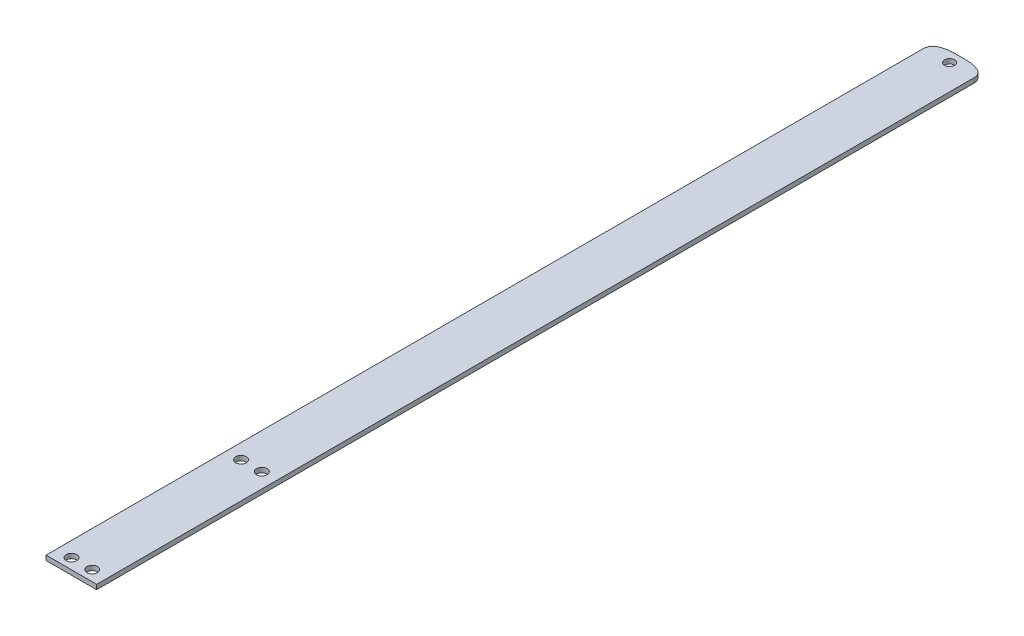
from build123d import *

# Parameters (mm, degrees)
SKETCH3_R           = 2.25
BOSS_EXTRUDE2_DEPTH = 2


with BuildPart() as part:
    # Sketch3 → Boss-Extrude2 (new body)
    with BuildSketch(Plane(origin=(0, 123.794401912, 0), x_dir=(-1, 0, 0), z_dir=(0, 1, 0))):
        with BuildLine():
            Line((0, -40), (0, -245))
            Line((0, -245), (0, -300.54))
            ThreePointArc((0, -300.54), (2.1, -302.64), (0, -304.74))
            Line((0, -304.74), (0, -307.135677029))
            add(Edge.make_bspline(
                [(0, -307.135677029), (3.525787284, -307.326518028), (6.349200001, -306.916747925), (8.470238152, -305.906366718)],
                knots=[0, 0, 0, 0, 0.308955345, 0.308955345, 0.308955345, 0.308955345], degree=3))
            ThreePointArc((8.470238152, -305.906366718), (10.132377315, -304.430468728), (10.75, -302.295164605))
            Line((10.75, -302.295164605), (10.75, -284.460908409))
            Line((10.75, -284.460908409), (10.75, -40))
            Line((10.75, -40), (10.75, 40))
            Line((10.75, 40), (10.75, 70.36))
            Line((10.75, 70.36), (0, 70.36))
            Line((0, 70.36), (0, 40))
            Line((0, 40), (0, -40))
        make_face()
        with Locations((4.4, -6.14)):
            Circle(SKETCH3_R, mode=Mode.SUBTRACT)
        with Locations((4.4, 65.86)):
            Circle(SKETCH3_R, mode=Mode.SUBTRACT)
    extrude(amount=BOSS_EXTRUDE2_DEPTH)

    # Mirror10: part across face


with BuildPart() as part_1:
    add(part.part)
    add(part.part.mirror(Plane(origin=(0, 124.794401912, -115.09), x_dir=(0, 0, 1), z_dir=(1, 0, 0))))


solid = part_1.part
